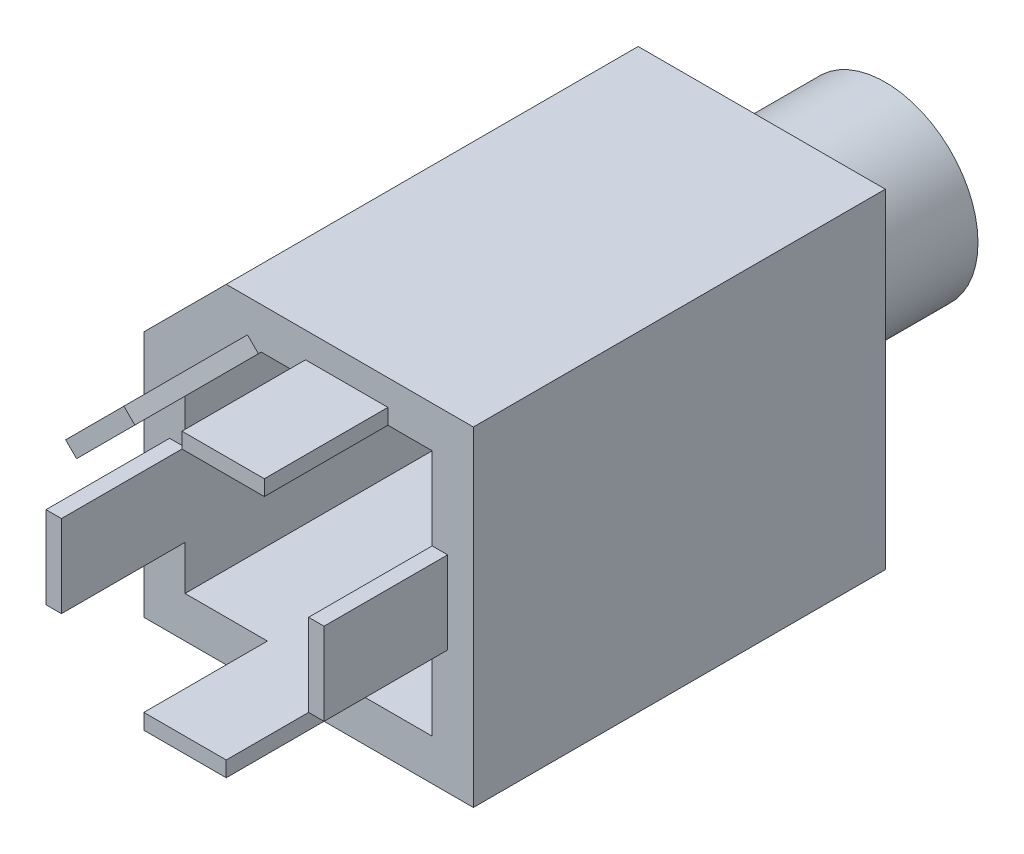
from build123d import *

# Parameters (mm, degrees)
ESQUISSE1_R         = 3.25
BOSS_EXTRU_1_DEPTH  = 2
BOSS_EXTRU_2_DEPTH  = 18
ESQUISSE3_R         = 4.5
ESQUISSE3_R_2       = 3.25
BOSS_EXTRU_3_DEPTH  = 8
ESQUISSE4_R         = 3.25
BOSS_EXTRU_4_DEPTH  = 1
BOSS_EXTRU_6_DEPTH  = 0.5
BOSS_EXTRU_7_DEPTH  = 0.5
BOSS_EXTRU_8_DEPTH  = 0.5
BOSS_EXTRU_9_DEPTH  = 0.5
ESQUISSE15_W        = 0.75
ESQUISSE15_H        = 4
ESQUISSE15_W_2      = 4
ESQUISSE15_H_2      = 0.75
BOSS_EXTRU_10_DEPTH = 6


with BuildPart() as part:
    # Esquisse1 → Boss.-Extru.1 (new body)
    with BuildSketch(Plane.XY):
        Polygon((0, 0), (-16, 0), (-16, 12), (-12, 16), (0, 16), align=None)
        with Locations((-8, 8)):
            Circle(ESQUISSE1_R, mode=Mode.SUBTRACT)
    extrude(amount=BOSS_EXTRU_1_DEPTH)

    # Esquisse2 → Boss.-Extru.2 (add)
    with BuildSketch(Plane.XY.offset(2)):
        Polygon((-16, 0), (0, 0), (0, 16), (-12, 16), (-16, 12), align=None)
        Polygon((-2, 2), (-2, 14), (-10.299397605, 14), (-14, 10.299397605), (-14, 2), align=None, mode=Mode.SUBTRACT)
    extrude(amount=BOSS_EXTRU_2_DEPTH)

    # Esquisse3 → Boss.-Extru.3 (add)
    with BuildSketch(Plane(origin=(0, 0, 0), x_dir=(-1, 0, 0), z_dir=(0, 0, -1))):
        with Locations((8, 8)):
            Circle(ESQUISSE3_R)
        with Locations((8, 8)):
            Circle(ESQUISSE3_R_2, mode=Mode.SUBTRACT)
    extrude(amount=BOSS_EXTRU_3_DEPTH)

    # Esquisse4 → Boss.-Extru.4 (add)
    with BuildSketch(Plane(origin=(0, 0, 0), x_dir=(-1, 0, 0), z_dir=(0, 0, -1))):
        Polygon((2.5, 5.328427125), (2.5, 10.671572875), (2.853553391, 10.318019485), (5.681980515, 13.146446609), (5.328427125, 13.5), (10.671572875, 13.5), (10.318019485, 13.146446609), (13.146446609, 10.318019485), (13.5, 10.671572875), (13.5, 5.328427125), (13.146446609, 5.681980515), (10.318019485, 2.853553391), (10.671572875, 2.5), (5.328427125, 2.5), (5.681980515, 2.853553391), (2.853553391, 5.681980515), align=None)
        with Locations((8, 8)):
            Circle(ESQUISSE4_R, mode=Mode.SUBTRACT)
    extrude(amount=BOSS_EXTRU_4_DEPTH)

    # Esquisse11 → Boss.-Extru.6 (add)
    with BuildSketch(Plane(origin=(-3.732233047, -3.732233047, 0), x_dir=(0, 0, 1), z_dir=(-0.707106781, -0.707106781, 0))):
        Polygon((0, 9.313708499), (-1, 9.313708499), (-2.326649916, 11.313708499), (-1, 13.313708499), (0, 13.313708499), align=None)
    extrude(amount=BOSS_EXTRU_6_DEPTH)

    # Esquisse12 → Boss.-Extru.7 (add)
    with BuildSketch(Plane(origin=(-4.267766953, 4.267766953, 0), x_dir=(0, 0, -1), z_dir=(0.707106781, -0.707106781, 0))):
        Polygon((0, 2), (1, 2), (2.326649916, 0), (1, -2), (0, -2), align=None)
    extrude(amount=BOSS_EXTRU_7_DEPTH)

    # Esquisse13 → Boss.-Extru.8 (add)
    with BuildSketch(Plane(origin=(3.732233047, 3.732233047, 0), x_dir=(0, 0, -1), z_dir=(0.707106781, 0.707106781, 0))):
        Polygon((0, 13.313708499), (1, 13.313708499), (2.326649916, 11.313708499), (1, 9.313708499), (0, 9.313708499), align=None)
    extrude(amount=BOSS_EXTRU_8_DEPTH)

    # Esquisse14 → Boss.-Extru.9 (add)
    with BuildSketch(Plane(origin=(-11.732233047, 11.732233047, 0), x_dir=(0, 0, 1), z_dir=(-0.707106781, 0.707106781, 0))):
        Polygon((0, -2), (-1, -2), (-2.326649916, 0), (-1, 2), (0, 2), align=None)
    extrude(amount=BOSS_EXTRU_9_DEPTH)

    # Esquisse15 → Boss.-Extru.10 (add)
    with BuildSketch(Plane.XY.offset(20)):
        with Locations((-14.375, 6.15)):
            Rectangle(ESQUISSE15_W, ESQUISSE15_H)
        with Locations((-8, 1.625)):
            Rectangle(ESQUISSE15_W_2, ESQUISSE15_H_2)
        with Locations((-1.625, 8)):
            Rectangle(ESQUISSE15_W, ESQUISSE15_H)
        with Locations((-6.15, 14.375)):
            Rectangle(ESQUISSE15_W_2, ESQUISSE15_H_2)
        Polygon((-10.437222619, 13.862174986), (-13.265649743, 11.033747861), (-13.795979829, 11.564077947), (-10.967552704, 14.392505072), align=None)
    extrude(amount=BOSS_EXTRU_10_DEPTH)


solid = part.part
